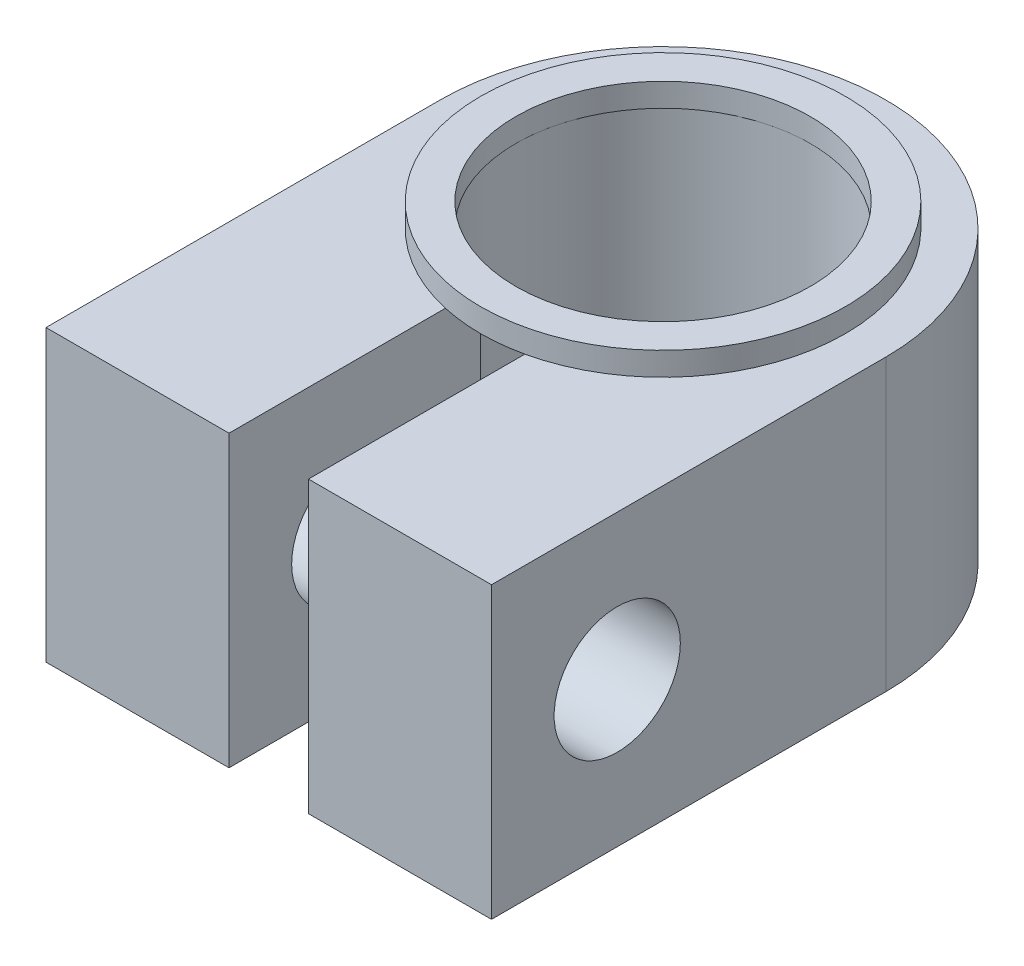
from build123d import *

# Parameters (mm, degrees)
CROQUIS1_R              = 4.765
CROQUIS1_W              = 9.53
CROQUIS1_H              = 4.65
SALIENTE_EXTRUIR1_DEPTH = 6.2
CROQUIS2_R              = 3.175
CORTAR_EXTRUIR1_DEPTH   = 6.2
CROQUIS3_W              = 1.7
CROQUIS3_H              = 5.8
CORTAR_EXTRUIR2_DEPTH   = 6.2
CROQUIS4_R              = 1.35
CORTAR_EXTRUIR3_DEPTH   = 10.53
CROQUIS5_R              = 3.9
SALIENTE_EXTRUIR2_DEPTH = 0.5
CROQUIS6_R              = 3.15
CORTAR_EXTRUIR4_DEPTH   = 7.7


with BuildPart() as part:
    # Croquis1 → Saliente-Extruir1 (new body)
    with BuildSketch(Plane(origin=(0, 0, 0), x_dir=(1, 0, 0), z_dir=(0, 1, 0))):
        with Locations((0, 6.11)):
            Circle(CROQUIS1_R)
        Rectangle(CROQUIS1_W, CROQUIS1_H)
        with BuildLine():
            ThreePointArc((4.765, 6.11), (0, 10.875), (-4.765, 6.11))
            ThreePointArc((-4.765, 6.11), (-4.271898488, 3.999050378), (-2.894650238, 2.325))
            Line((-2.894650238, 2.325), (2.894650238, 2.325))
            ThreePointArc((2.894650238, 2.325), (4.271898488, 3.999050378), (4.765, 6.11))
        make_face()
        with BuildLine():
            Line((2.894650238, 2.325), (-2.894650238, 2.325))
            ThreePointArc((-2.894650238, 2.325), (0, 1.345), (2.894650238, 2.325))
        make_face()
        with BuildLine():
            Line((-4.765, 6.11), (-4.765, 2.325))
            Line((-4.765, 2.325), (-2.894650238, 2.325))
            ThreePointArc((-2.894650238, 2.325), (-4.271898488, 3.999050378), (-4.765, 6.11))
        make_face()
        with BuildLine():
            Line((4.765, 2.325), (4.765, 6.11))
            ThreePointArc((4.765, 6.11), (4.271898488, 3.999050378), (2.894650238, 2.325))
            Line((2.894650238, 2.325), (4.765, 2.325))
        make_face()
    extrude(amount=SALIENTE_EXTRUIR1_DEPTH)

    # Croquis2 → Cortar-Extruir1 (cut)
    with BuildSketch(Plane(origin=(0, 6.2, 0), x_dir=(1, 0, 0), z_dir=(0, 1, 0))):
        with Locations((0, 6.11)):
            Circle(CROQUIS2_R)
    extrude(amount=-CORTAR_EXTRUIR1_DEPTH, mode=Mode.SUBTRACT)

    # Croquis3 → Cortar-Extruir2 (cut)
    with BuildSketch(Plane(origin=(0, 6.2, 0), x_dir=(1, 0, 0), z_dir=(0, 1, 0))):
        with Locations((0, 0.575)):
            Rectangle(CROQUIS3_W, CROQUIS3_H)
    extrude(amount=-CORTAR_EXTRUIR2_DEPTH, mode=Mode.SUBTRACT)

    # Croquis4 → Cortar-Extruir3 (cut, through all)
    with BuildSketch(Plane(origin=(4.765, 0, 0), x_dir=(0, 0, -1), z_dir=(1, 0, 0))):
        with Locations((0.365, 3.1)):
            Circle(CROQUIS4_R)
    extrude(amount=-CORTAR_EXTRUIR3_DEPTH, mode=Mode.SUBTRACT)

    # Croquis5 → Saliente-Extruir2 (add)
    with BuildSketch(Plane(origin=(0, 6.2, 0), x_dir=(1, 0, 0), z_dir=(0, 1, 0))):
        with Locations((0, 6.11)):
            Circle(CROQUIS5_R)
    extrude(amount=SALIENTE_EXTRUIR2_DEPTH)

    # Croquis6 → Cortar-Extruir4 (cut, through all)
    with BuildSketch(Plane(origin=(0, 6.7, 0), x_dir=(1, 0, 0), z_dir=(0, 1, 0))):
        with Locations((0, 6.11)):
            Circle(CROQUIS6_R)
    extrude(amount=-CORTAR_EXTRUIR4_DEPTH, mode=Mode.SUBTRACT)


solid = part.part
